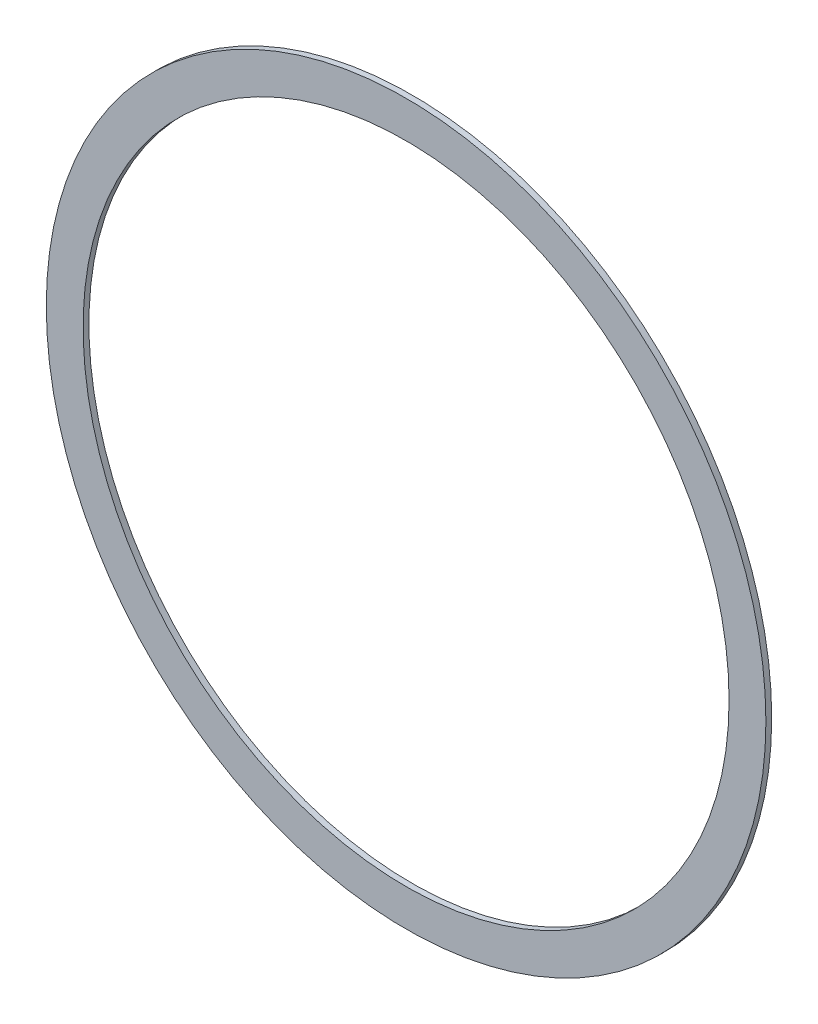
from build123d import *

# Parameters (mm, degrees)
SKETCH1_R           = 278.5
SKETCH1_R_2         = 250
BOSS_EXTRUDE1_DEPTH = 2.25


with BuildPart() as part:
    # Sketch1 → Boss-Extrude1 (new body, symmetric)
    with BuildSketch(Plane.XY):
        Circle(SKETCH1_R)
        Circle(SKETCH1_R_2, mode=Mode.SUBTRACT)
    extrude(amount=BOSS_EXTRUDE1_DEPTH, both=True)


solid = part.part
